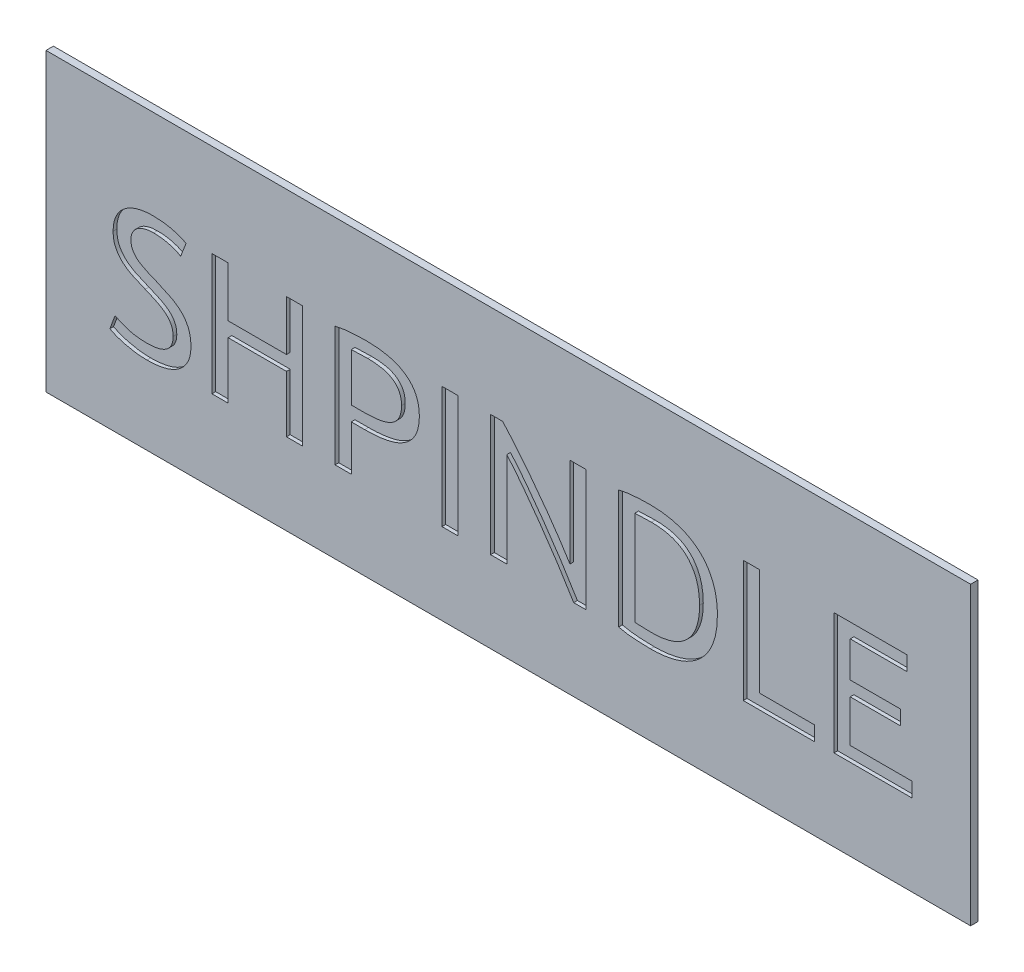
from build123d import *

# Parameters (mm, degrees)
SKETCH1_W           = 25
SKETCH1_H           = 8
BOSS_EXTRUDE1_DEPTH = 0.1
SKETCH2_W           = 0.438008889
SKETCH2_H           = 3.285066666
CUT_EXTRUDE1_DEPTH  = 0.1


with BuildPart() as part:
    # Sketch1 → Boss-Extrude1 (new body, symmetric)
    with BuildSketch(Plane.XY):
        Rectangle(SKETCH1_W, SKETCH1_H)
    extrude(amount=BOSS_EXTRUDE1_DEPTH, both=True)

    # Sketch2 → Cut-Extrude1 (cut)
    with BuildSketch(Plane.XY.offset(0.1)):
        with BuildLine():
            add(Edge.make_bspline(
                [(-9.772033954, -1.490949353), (-9.743502752, -1.490599935), (-9.687967645, -1.489919803), (-9.607603627, -1.483406036), (-9.532461498, -1.474521816), (-9.463320861, -1.459743204), (-9.399297403, -1.442355619), (-9.34087203, -1.420385294), (-9.287832616, -1.394709651), (-9.241026462, -1.363950527), (-9.198712558, -1.330837537), (-9.162682243, -1.292290005), (-9.131766789, -1.250152488), (-9.107313823, -1.203519991), (-9.086697344, -1.153835797), (-9.07358577, -1.099343788), (-9.065145378, -1.041116288), (-9.064183831, -1.000958648), (-9.063691454, -0.980395242)],
                knots=[0, 0, 0, 0, 8.5573e-05, 0.000166566, 0.000241777, 0.000312378, 0.000378467, 0.000440626, 0.000499392, 0.000554823, 0.000608372, 0.000660174, 0.000712604, 0.000764658, 0.000817781, 0.000873554, 0.000932303, 0.000993959, 0.000993959, 0.000993959, 0.000993959], degree=3))
            add(Edge.make_bspline(
                [(-9.063691454, -0.980395242), (-9.06457664, -0.955045462), (-9.066283987, -0.906150813), (-9.076616584, -0.835485541), (-9.097097937, -0.771344535), (-9.123786537, -0.712348974), (-9.158098048, -0.658743303), (-9.197046912, -0.608786178), (-9.241305855, -0.562197086), (-9.309203692, -0.505583928), (-9.404649708, -0.440616509), (-9.533207273, -0.375022347), (-9.672165611, -0.313048436), (-9.768088773, -0.272356351), (-9.817203621, -0.251521075)],
                knots=[0, 0, 0, 0, 7.6078e-05, 0.000146739, 0.00021341, 0.000277414, 0.000340456, 0.000403843, 0.000467255, 0.000532803, 0.000668719, 0.000812603, 0.000965136, 0.001125185, 0.001125185, 0.001125185, 0.001125185], degree=3))
            add(Edge.make_bspline(
                [(-9.817203621, -0.251521075), (-9.874157289, -0.228616435), (-9.986902767, -0.183274409), (-10.124453019, -0.121769563), (-10.228824876, -0.068170207), (-10.300961299, -0.024056763), (-10.36807035, 0.023082834), (-10.430390958, 0.073546762), (-10.48568147, 0.129577605), (-10.53657124, 0.188948894), (-10.579291611, 0.254817286), (-10.617719223, 0.324723049), (-10.64830067, 0.401536187), (-10.669044662, 0.4860386), (-10.682353502, 0.577762885), (-10.683653772, 0.641557257), (-10.684324343, 0.674457091)],
                knots=[0, 0, 0, 0, 0.000184157, 0.000364556, 0.000451799, 0.000535957, 0.000617984, 0.000697726, 0.000776123, 0.000853849, 0.000931863, 0.001011173, 0.001092891, 0.001179039, 0.001271665, 0.001370302, 0.001370302, 0.001370302, 0.001370302], degree=3))
            add(Edge.make_bspline(
                [(-10.684324343, 0.674457091), (-10.683332092, 0.70894351), (-10.681399424, 0.776114786), (-10.668453489, 0.874121135), (-10.645947035, 0.966462925), (-10.613719191, 1.052696857), (-10.572955445, 1.133123038), (-10.523318848, 1.207732136), (-10.464150438, 1.276358495), (-10.395903658, 1.338689969), (-10.320345922, 1.394668338), (-10.237083782, 1.442909566), (-10.147438986, 1.483823972), (-10.050791425, 1.517583902), (-9.94742582, 1.543325522), (-9.837097624, 1.561462533), (-9.720293034, 1.573641185), (-9.639979207, 1.574614722), (-9.598883566, 1.575112869)],
                knots=[0, 0, 0, 0, 0.000103454, 0.000201503, 0.000295951, 0.000387988, 0.000477056, 0.00056589, 0.000656156, 0.000748186, 0.000842634, 0.000937712, 0.001036323, 0.001137837, 0.001244402, 0.001355452, 0.00147306, 0.001596297, 0.001596297, 0.001596297, 0.001596297], degree=3))
            add(Edge.make_bspline(
                [(-9.598883566, 1.575112869), (-9.550956451, 1.574276695), (-9.457238555, 1.572641619), (-9.319973774, 1.56127072), (-9.189715815, 1.540567301), (-9.06775173, 1.512842711), (-8.95750838, 1.480159402), (-8.860763599, 1.447367553), (-8.7803153, 1.411883835), (-8.734268365, 1.383912006), (-8.713284343, 1.37116498)],
                knots=[0, 0, 0, 0, 0.00014378, 0.000281152, 0.000412797, 0.000539142, 0.00065609, 0.000757604, 0.00084551, 0.000919109, 0.000919109, 0.000919109, 0.000919109], degree=3))
            Line((-8.713284343, 1.37116498), (-8.859743566, 1.000910591))
            add(Edge.make_bspline(
                [(-8.859743566, 1.000910591), (-8.877585445, 1.011518858), (-8.91615112, 1.034448895), (-8.982796929, 1.063852611), (-9.060640405, 1.093849724), (-9.149551473, 1.12298797), (-9.247932133, 1.149489563), (-9.355427159, 1.167234179), (-9.470390115, 1.179496174), (-9.549800391, 1.180426205), (-9.590670899, 1.180904869)],
                knots=[0, 0, 0, 0, 6.2223e-05, 0.000134496, 0.000218126, 0.000312488, 0.000415075, 0.000523427, 0.000638992, 0.000761545, 0.000761545, 0.000761545, 0.000761545], degree=3))
            add(Edge.make_bspline(
                [(-9.590670899, 1.180904869), (-9.632073277, 1.179787973), (-9.712760106, 1.177611315), (-9.828087063, 1.155185973), (-9.932996602, 1.120659328), (-10.009369127, 1.077376461), (-10.062779978, 1.036686828), (-10.09790402, 1.002169812), (-10.128870415, 0.96355043), (-10.15554568, 0.921228306), (-10.177322511, 0.875233511), (-10.19112882, 0.82470201), (-10.201472841, 0.770920806), (-10.202161923, 0.733369054), (-10.202514566, 0.714151647)],
                knots=[0, 0, 0, 0, 0.000124063, 0.00024178, 0.000351079, 0.000454049, 0.00050333, 0.00055221, 0.000601377, 0.000651506, 0.00070203, 0.000753359, 0.000808268, 0.000865822, 0.000865822, 0.000865822, 0.000865822], degree=3))
            add(Edge.make_bspline(
                [(-10.202514566, 0.714151647), (-10.201800671, 0.6926772), (-10.200434649, 0.651586307), (-10.191615788, 0.59220919), (-10.176143216, 0.53825658), (-10.153810922, 0.489219818), (-10.125078624, 0.445190127), (-10.091840464, 0.403935155), (-10.054417239, 0.364504979), (-9.994947917, 0.316663391), (-9.910481878, 0.26095657), (-9.796099244, 0.201375165), (-9.668071313, 0.14514564), (-9.578012084, 0.109322285), (-9.531129066, 0.090673369)],
                knots=[0, 0, 0, 0, 6.4424e-05, 0.000123273, 0.000179585, 0.00023226, 0.000284278, 0.000336865, 0.000391074, 0.000446981, 0.000565426, 0.000694011, 0.000833406, 0.000984769, 0.000984769, 0.000984769, 0.000984769], degree=3))
            add(Edge.make_bspline(
                [(-9.531129066, 0.090673369), (-9.464993322, 0.062626903), (-9.336946118, 0.008325381), (-9.182430881, -0.064901673), (-9.067334718, -0.125529689), (-8.988331061, -0.1747212), (-8.915729453, -0.228966576), (-8.848864932, -0.28727691), (-8.788231855, -0.350397368), (-8.734332592, -0.419124218), (-8.688488182, -0.494119927), (-8.649830176, -0.575005208), (-8.618302323, -0.663071026), (-8.597097307, -0.759868812), (-8.583824897, -0.865275168), (-8.582545308, -0.938376456), (-8.581881677, -0.976288909)],
                knots=[0, 0, 0, 0, 0.000215497, 0.000417229, 0.000512762, 0.00060562, 0.000696096, 0.000784364, 0.000871494, 0.00095829, 0.001045854, 0.001134627, 0.001226839, 0.001325792, 0.001431308, 0.001544991, 0.001544991, 0.001544991, 0.001544991], degree=3))
            add(Edge.make_bspline(
                [(-8.581881677, -0.976288909), (-8.58276525, -1.011697537), (-8.584488801, -1.080767744), (-8.598972901, -1.181350795), (-8.623488377, -1.275526626), (-8.658156598, -1.363423863), (-8.701828882, -1.445285765), (-8.75592859, -1.520494157), (-8.819396324, -1.589656323), (-8.892960502, -1.651456494), (-8.974445405, -1.707466072), (-9.065297686, -1.754211711), (-9.162913604, -1.795757622), (-9.269508129, -1.82814533), (-9.383327903, -1.854376057), (-9.50565467, -1.871281407), (-9.635354533, -1.88377871), (-9.724777816, -1.884689819), (-9.770665177, -1.885157353)],
                knots=[0, 0, 0, 0, 0.000106188, 0.000207138, 0.000304082, 0.000397493, 0.000489966, 0.000581697, 0.000674694, 0.000770825, 0.000869344, 0.000970675, 0.001076809, 0.001187205, 0.00130442, 0.001426857, 0.00155741, 0.001695015, 0.001695015, 0.001695015, 0.001695015], degree=3))
            add(Edge.make_bspline(
                [(-9.770665177, -1.885157353), (-9.832085975, -1.883868189), (-9.950226346, -1.881388535), (-10.119282892, -1.861984285), (-10.271439897, -1.832424389), (-10.407035626, -1.800730491), (-10.52454011, -1.763146305), (-10.61120477, -1.730622673), (-10.671293098, -1.704243683), (-10.70886239, -1.685115108), (-10.742399778, -1.669362531), (-10.762619534, -1.658259797), (-10.771926121, -1.65314952)],
                knots=[0, 0, 0, 0, 0.000184228, 0.000354355, 0.000509657, 0.000649091, 0.000771818, 0.000879476, 0.000926659, 0.000968591, 0.001005933, 0.001037777, 0.001037777, 0.001037777, 0.001037777], degree=3))
            Line((-10.771926121, -1.65314952), (-10.634363954, -1.278104409))
            add(Edge.make_bspline(
                [(-10.634363954, -1.278104409), (-10.614174857, -1.288831063), (-10.569902821, -1.312353206), (-10.494906236, -1.345285131), (-10.406437285, -1.380879541), (-10.304815044, -1.418051014), (-10.189572155, -1.451533965), (-10.061069311, -1.473723771), (-9.920667484, -1.488602369), (-9.822950152, -1.490145366), (-9.772033954, -1.490949353)],
                knots=[0, 0, 0, 0, 6.8565e-05, 0.000150355, 0.000245544, 0.000354652, 0.000474888, 0.000604967, 0.00074532, 0.000898014, 0.000898014, 0.000898014, 0.000898014], degree=3))
        make_face()
        Polygon((-5.997629232, 1.487511091), (-5.559620343, 1.487511091), (-5.559620343, -1.797555575), (-5.997629232, -1.797555575), (-5.997629232, -0.264524464), (-7.574461232, -0.264524464), (-7.574461232, -1.797555575), (-8.012470121, -1.797555575), (-8.012470121, 1.487511091), (-7.574461232, 1.487511091), (-7.574461232, 0.129683536), (-5.997629232, 0.129683536), align=None)
        with BuildLine():
            add(Edge.make_bspline(
                [(-3.823325732, 1.53131198), (-3.768093787, 1.530571856), (-3.660679258, 1.529132471), (-3.504367644, 1.516625163), (-3.357778567, 1.496506203), (-3.221188905, 1.467888051), (-3.094367764, 1.4312646), (-2.977804088, 1.385082366), (-2.870355231, 1.332078803), (-2.773238061, 1.270180206), (-2.686394486, 1.200449448), (-2.610985475, 1.121866753), (-2.547874292, 1.034751113), (-2.494784059, 0.940302), (-2.455643488, 0.836706275), (-2.426944232, 0.725665231), (-2.408488415, 0.606630804), (-2.406816202, 0.524417968), (-2.405956343, 0.482143813)],
                knots=[0, 0, 0, 0, 0.000165673, 0.000322199, 0.000470091, 0.000609284, 0.000740523, 0.000865579, 0.000984945, 0.001099427, 0.001210374, 0.001318319, 0.001425092, 0.001532314, 0.00164238, 0.001756254, 0.001875983, 0.002002713, 0.002002713, 0.002002713, 0.002002713], degree=3))
            add(Edge.make_bspline(
                [(-2.405956343, 0.482143813), (-2.406994718, 0.436442371), (-2.409008674, 0.347803154), (-2.428582496, 0.220200143), (-2.459539233, 0.102481905), (-2.504470338, -0.004355164), (-2.560946861, -0.101370476), (-2.629600106, -0.188165249), (-2.708755023, -0.266414829), (-2.800041963, -0.334021551), (-2.901294818, -0.393102309), (-3.013042362, -0.443238878), (-3.135212613, -0.483717185), (-3.267010333, -0.516580795), (-3.408259091, -0.540588333), (-3.558338334, -0.558196987), (-3.717301155, -0.569483201), (-3.826271832, -0.570572026), (-3.882183177, -0.571130687)],
                knots=[0, 0, 0, 0, 0.000137016, 0.000265747, 0.000386277, 0.000501307, 0.000612347, 0.000722014, 0.000832356, 0.00094528, 0.001061837, 0.001183445, 0.001312001, 0.001447447, 0.001590568, 0.001741502, 0.001900657, 0.002068367, 0.002068367, 0.002068367, 0.002068367], degree=3))
            Line((-3.882183177, -0.571130687), (-4.245593677, -0.571130687))
            Line((-4.245593677, -0.571130687), (-4.245593677, -1.797555575))
            Line((-4.245593677, -1.797555575), (-4.683602566, -1.797555575))
            Line((-4.683602566, -1.797555575), (-4.683602566, 1.45123848))
            add(Edge.make_bspline(
                [(-4.683602566, 1.45123848), (-4.650822178, 1.458878062), (-4.583773647, 1.474503953), (-4.479316237, 1.491981113), (-4.369446011, 1.505442002), (-4.255731705, 1.515280861), (-4.141865397, 1.522855769), (-4.031168084, 1.527122997), (-3.925557724, 1.531259152), (-3.856864797, 1.531294649), (-3.823325732, 1.53131198)],
                knots=[0, 0, 0, 0, 0.000100956, 0.000206494, 0.000317528, 0.000432962, 0.000548869, 0.000659843, 0.000765295, 0.000865902, 0.000865902, 0.000865902, 0.000865902], degree=3))
        make_face()
        with BuildLine():
            add(Edge.make_bspline(
                [(-3.798003343, 1.13710398), (-3.843859059, 1.137045178), (-3.929876916, 1.136934875), (-4.050355605, 1.134276264), (-4.15373689, 1.129747918), (-4.216858357, 1.124926643), (-4.245593677, 1.122731813)],
                knots=[0, 0, 0, 0, 0.000137564, 0.000258047, 0.000361501, 0.000447954, 0.000447954, 0.000447954, 0.000447954], degree=3))
            Line((-4.245593677, 1.122731813), (-4.245593677, -0.176922687))
            Line((-4.245593677, -0.176922687), (-3.901346066, -0.176922687))
            add(Edge.make_bspline(
                [(-3.901346066, -0.176922687), (-3.863014545, -0.176484005), (-3.788364878, -0.175629683), (-3.679442793, -0.170299309), (-3.576447723, -0.160757767), (-3.479304362, -0.147299753), (-3.388527876, -0.129480856), (-3.30514647, -0.105156137), (-3.228787467, -0.076878283), (-3.159639941, -0.042398862), (-3.097357738, -0.002345838), (-3.043377934, 0.045813836), (-2.996346064, 0.100156367), (-2.956902184, 0.162095384), (-2.92474909, 0.23181454), (-2.903728192, 0.310982041), (-2.889420169, 0.398356723), (-2.888333065, 0.459722117), (-2.887766121, 0.491725258)],
                knots=[0, 0, 0, 0, 0.000114996, 0.000223951, 0.000327056, 0.000425198, 0.000518078, 0.000604284, 0.000685508, 0.000762025, 0.000835675, 0.000906947, 0.000978285, 0.001050616, 0.001126571, 0.001207607, 0.001295596, 0.001391498, 0.001391498, 0.001391498, 0.001391498], degree=3))
            add(Edge.make_bspline(
                [(-2.887766121, 0.491725258), (-2.888637026, 0.522354796), (-2.89030393, 0.580979449), (-2.904226952, 0.664646067), (-2.926302768, 0.740309866), (-2.959043512, 0.807327829), (-2.99959224, 0.866842061), (-3.045752341, 0.920490373), (-3.099668377, 0.966825052), (-3.159184282, 1.007183652), (-3.224648805, 1.041179598), (-3.294620107, 1.070164626), (-3.369895662, 1.092705223), (-3.477993472, 1.115020934), (-3.621263814, 1.133685137), (-3.738167048, 1.135946509), (-3.798003343, 1.13710398)],
                knots=[0, 0, 0, 0, 9.1833e-05, 0.000175768, 0.00025371, 0.000327478, 0.00039847, 0.00046929, 0.000539145, 0.000611087, 0.000684559, 0.000760053, 0.000837996, 0.000919877, 0.001091012, 0.001270453, 0.001270453, 0.001270453, 0.001270453], degree=3))
        make_face(mode=Mode.SUBTRACT)
        with Locations((-1.573739455, -0.155022242)):
            Rectangle(SKETCH2_W, SKETCH2_H)
        with BuildLine():
            add(Edge.make_bspline(
                [(1.76813149, -1.797555575), (1.750140835, -1.76742361), (1.712996, -1.705210926), (1.655008485, -1.609506705), (1.592395919, -1.509018186), (1.503809222, -1.365314782), (1.3853584, -1.178204151), (1.233552625, -0.948731167), (1.074404149, -0.712833173), (0.90858352, -0.475424584), (0.743229985, -0.238419315), (0.575704328, -0.010505877), (0.412231367, 0.207403969), (0.277888499, 0.380123458), (0.174236242, 0.510835069), (0.100507499, 0.601793113), (0.029444741, 0.686778211), (-0.017797143, 0.740699188), (-0.040708343, 0.766849591)],
                knots=[0, 0, 0, 0, 0.000105283, 0.000217374, 0.000335696, 0.000460475, 0.000723819, 0.001000004, 0.001285872, 0.001577481, 0.001868751, 0.002152793, 0.002426002, 0.00268597, 0.002809207, 0.002926461, 0.003037223, 0.003141522, 0.003141522, 0.003141522, 0.003141522], degree=3))
            Line((-0.040708343, 0.766849591), (-0.040708343, -1.797555575))
            Line((-0.040708343, -1.797555575), (-0.478717232, -1.797555575))
            Line((-0.478717232, -1.797555575), (-0.478717232, 1.487511091))
            Line((-0.478717232, 1.487511091), (-0.154316899, 1.487511091))
            add(Edge.make_bspline(
                [(-0.154316899, 1.487511091), (-0.116216501, 1.446656647), (-0.037759838, 1.362528828), (0.078780495, 1.228603876), (0.200008814, 1.085619886), (0.367342126, 0.881320221), (0.577716174, 0.614791122), (0.825107372, 0.287185084), (1.065960453, -0.040843861), (1.256023822, -0.313201304), (1.398630287, -0.523859423), (1.496586362, -0.671492308), (1.585798141, -0.810302051), (1.640994011, -0.900678995), (1.667526323, -0.944122631)],
                knots=[0, 0, 0, 0, 0.000167579, 0.00034508, 0.00053252, 0.000729949, 0.00113729, 0.001551076, 0.001961465, 0.002358085, 0.002547336, 0.002724624, 0.002889602, 0.003042313, 0.003042313, 0.003042313, 0.003042313], degree=3))
            Line((1.667526323, -0.944122631), (1.667526323, 1.487511091))
            Line((1.667526323, 1.487511091), (2.105535212, 1.487511091))
            Line((2.105535212, 1.487511091), (2.105535212, -1.797555575))
            Line((2.105535212, -1.797555575), (1.76813149, -1.797555575))
        make_face()
        with BuildLine():
            add(Edge.make_bspline(
                [(5.653407212, -0.155022242), (5.653019653, -0.190163127), (5.652253993, -0.259587196), (5.645994913, -0.361887636), (5.635803216, -0.460771174), (5.621469369, -0.556018612), (5.603033541, -0.647855378), (5.580473905, -0.736279652), (5.553801506, -0.821295118), (5.513208891, -0.928742677), (5.452868205, -1.05463997), (5.36730739, -1.194444123), (5.266563441, -1.319487234), (5.153032587, -1.431362293), (5.026177315, -1.528322527), (4.888521723, -1.6135443), (4.738146373, -1.683627241), (4.577121045, -1.741740064), (4.406233244, -1.786780563), (4.226398278, -1.817437643), (4.03874517, -1.838433105), (3.910556818, -1.840369815), (3.845251768, -1.841356464)],
                knots=[0, 0, 0, 0, 0.000105416, 0.000208259, 0.000307344, 0.000403554, 0.000497105, 0.000588234, 0.000677197, 0.000764268, 0.000932633, 0.001095208, 0.001254892, 0.001413146, 0.001572213, 0.001732904, 0.001897916, 0.002068945, 0.002245904, 0.002427283, 0.002615852, 0.002811685, 0.002811685, 0.002811685, 0.002811685], degree=3))
            add(Edge.make_bspline(
                [(3.845251768, -1.841356464), (3.811488431, -1.840956338), (3.742356299, -1.840137061), (3.636228273, -1.837795452), (3.525170354, -1.831601897), (3.41076017, -1.825668662), (3.296623879, -1.81543683), (3.186520029, -1.802056541), (3.081856424, -1.784463169), (3.0145637, -1.768911766), (2.98155299, -1.761282964)],
                knots=[0, 0, 0, 0, 0.000101299, 0.000207414, 0.000318421, 0.000434968, 0.000551084, 0.000662118, 0.000767656, 0.00086928, 0.00086928, 0.00086928, 0.00086928], degree=3))
            Line((2.98155299, -1.761282964), (2.98155299, 1.45123848))
            add(Edge.make_bspline(
                [(2.98155299, 1.45123848), (3.014563605, 1.458868972), (3.081856136, 1.47442382), (3.186521257, 1.49199012), (3.296618916, 1.50548098), (3.410793652, 1.515277656), (3.525116527, 1.522833285), (3.636268067, 1.527142704), (3.742335675, 1.531257105), (3.811484631, 1.531293975), (3.845251768, 1.53131198)],
                knots=[0, 0, 0, 0, 0.000101624, 0.000207162, 0.000318196, 0.000434312, 0.000550902, 0.000661876, 0.000768012, 0.000869303, 0.000869303, 0.000869303, 0.000869303], degree=3))
            add(Edge.make_bspline(
                [(3.845251768, 1.53131198), (3.910544278, 1.530221428), (4.038684407, 1.528081159), (4.226531132, 1.508554554), (4.406143634, 1.476446408), (4.577142585, 1.431785836), (4.738110641, 1.373511559), (4.888747245, 1.30363884), (5.025958807, 1.217475489), (5.153101095, 1.120711478), (5.26628454, 1.00876041), (5.367762355, 0.884269387), (5.452609126, 0.743974674), (5.51326623, 0.61803926), (5.553655345, 0.510746609), (5.580606329, 0.426049441), (5.603011586, 0.337803868), (5.621475499, 0.245976089), (5.635801502, 0.150726141), (5.645995395, 0.051843306), (5.652253867, -0.050457328), (5.65301961, -0.119881371), (5.653407212, -0.155022242)],
                knots=[0, 0, 0, 0, 0.000195832, 0.000384331, 0.00056583, 0.000742789, 0.000913818, 0.001078829, 0.00123988, 0.001398948, 0.001557201, 0.001716352, 0.00187951, 0.002047875, 0.002134946, 0.002223256, 0.002314385, 0.002407936, 0.002504146, 0.002603231, 0.002706074, 0.00281149, 0.00281149, 0.00281149, 0.00281149], degree=3))
        make_face()
        with BuildLine():
            add(Edge.make_bspline(
                [(3.870574157, -1.447148464), (3.923539517, -1.446107582), (4.026066768, -1.444092704), (4.174890348, -1.428304701), (4.313205977, -1.401861878), (4.441585939, -1.365212218), (4.559194494, -1.317031827), (4.66697669, -1.259099187), (4.763526681, -1.189019101), (4.850241621, -1.109413416), (4.926504697, -1.019835507), (4.992588662, -0.921306907), (5.048087883, -0.813984608), (5.093127353, -0.69823037), (5.128866417, -0.574580334), (5.153896295, -0.442387498), (5.169201814, -0.301616869), (5.170784058, -0.204794983), (5.171597434, -0.155022242)],
                knots=[0, 0, 0, 0, 0.000158873, 0.000307536, 0.000448336, 0.000580888, 0.000707345, 0.000828929, 0.000947075, 0.001064288, 0.001181278, 0.001299154, 0.001419453, 0.001542985, 0.001671212, 0.001805032, 0.001946138, 0.002095411, 0.002095411, 0.002095411, 0.002095411], degree=3))
            add(Edge.make_bspline(
                [(5.171597434, -0.155022242), (5.170784299, -0.105249376), (5.169202524, -0.008427246), (5.153893693, 0.13234166), (5.128875469, 0.264540558), (5.093095566, 0.388169352), (5.04827385, 0.50380979), (4.99238112, 0.61069669), (4.926531486, 0.70912307), (4.850227721, 0.798667884), (4.763555713, 0.878340765), (4.66678329, 0.948245346), (4.559404743, 1.007143394), (4.441554868, 1.055111175), (4.313215036, 1.091833885), (4.174887722, 1.118255437), (4.026067493, 1.13404954), (3.923539764, 1.136063548), (3.870574157, 1.13710398)],
                knots=[0, 0, 0, 0, 0.000149274, 0.000290379, 0.000424199, 0.000552427, 0.000675959, 0.00079565, 0.000913526, 0.001030517, 0.001147729, 0.001265875, 0.001387789, 0.001514245, 0.001646798, 0.001787597, 0.001936261, 0.002095133, 0.002095133, 0.002095133, 0.002095133], degree=3))
            add(Edge.make_bspline(
                [(3.870574157, 1.13710398), (3.840003287, 1.137257145), (3.782507933, 1.137545207), (3.701532064, 1.135661344), (3.631475885, 1.134779669), (3.571954127, 1.132334088), (3.522176488, 1.130803637), (3.480953268, 1.127409992), (3.44755124, 1.126080772), (3.42799465, 1.123740804), (3.419561879, 1.122731813)],
                knots=[0, 0, 0, 0, 9.1708e-05, 0.000172478, 0.000242983, 0.000301876, 0.000351195, 0.000392349, 0.000425947, 0.000451417, 0.000451417, 0.000451417, 0.000451417], degree=3))
            Line((3.419561879, 1.122731813), (3.419561879, -1.432776298))
            add(Edge.make_bspline(
                [(3.419561879, -1.432776298), (3.428003794, -1.433443689), (3.447626042, -1.434994962), (3.480879381, -1.438093617), (3.522239646, -1.439510474), (3.571917961, -1.44284418), (3.631484653, -1.444661343), (3.701529154, -1.445759867), (3.782508823, -1.447573163), (3.840003596, -1.447295892), (3.870574157, -1.447148464)],
                knots=[0, 0, 0, 0, 2.5405e-05, 5.9052e-05, 0.000100167, 0.000149519, 0.000208412, 0.000278917, 0.000359687, 0.000451395, 0.000451395, 0.000451395, 0.000451395], degree=3))
        make_face(mode=Mode.SUBTRACT)
        Polygon((8.281460546, -1.403347575), (8.281460546, -1.797555575), (6.354221434, -1.797555575), (6.354221434, 1.487511091), (6.792230323, 1.487511091), (6.792230323, -1.403347575), align=None)
        Polygon((8.807071212, -1.797555575), (8.807071212, 1.487511091), (10.778111212, 1.487511091), (10.778111212, 1.093303091), (9.245080101, 1.093303091), (9.245080101, 0.129683536), (10.602907657, 0.129683536), (10.602907657, -0.264524464), (9.245080101, -0.264524464), (9.245080101, -1.403347575), (10.909513879, -1.403347575), (10.909513879, -1.797555575), align=None)
    extrude(amount=-CUT_EXTRUDE1_DEPTH, mode=Mode.SUBTRACT)


solid = part.part
